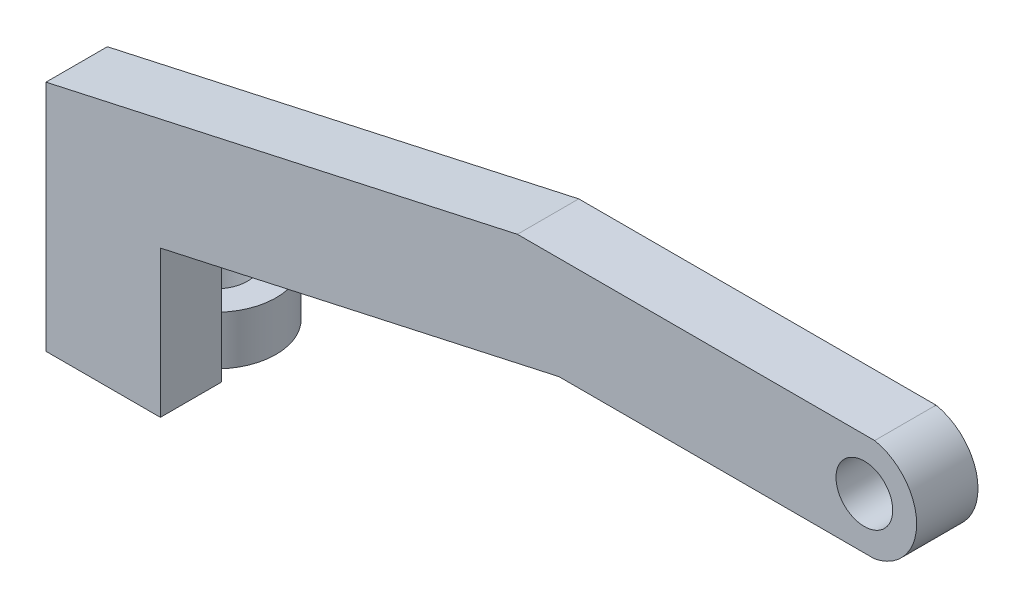
from build123d import *

# Parameters (mm, degrees)
SKETCH1_R           = 1.155127989
BOSS_EXTRUDE1_DEPTH = 2.5
SKETCH4_R           = 1.3
BOSS_EXTRUDE5_DEPTH = 2


with BuildPart() as part:
    # Sketch1 → Boss-Extrude1 (new body)
    with BuildSketch(Plane.XY):
        with BuildLine():
            Line((24.615399121, 0), (37.479574188, 0))
            ThreePointArc((37.479574188, 0), (39.18992359, 2.089117865), (37.479574188, 4.178235731))
            Line((37.479574188, 4.178235731), (22.923117505, 4.178235731))
            Line((22.923117505, 4.178235731), (3.715813686, -0.056552658))
            Line((3.715813686, -0.056552658), (3.715813686, -9.556552658))
            Line((3.715813686, -9.556552658), (8.3762383, -9.556552658))
            Line((8.3762383, -9.556552658), (8.3762383, -3.580378086))
            Line((8.3762383, -3.580378086), (24.615399121, 0))
        make_face()
        with Locations((37.058865303, 2.089117865)):
            Circle(SKETCH1_R, mode=Mode.SUBTRACT)
    extrude(amount=BOSS_EXTRUDE1_DEPTH)


with BuildPart() as body_2:
    # Sketch4 → Boss-Extrude5 (new body)
    with BuildSketch(Plane.XZ.offset(9.556552658)):
        with BuildLine():
            Line((7.3762383, 0), (4.715813686, 0))
            ThreePointArc((4.715813686, 0), (6.046025993, -4.544205624), (7.3762383, 0))
        make_face()
        with Locations((6.046025993, -2.077408191)):
            Circle(SKETCH4_R, mode=Mode.SUBTRACT)
    extrude(amount=-BOSS_EXTRUDE5_DEPTH)


solid = Compound([part.part, body_2.part])
